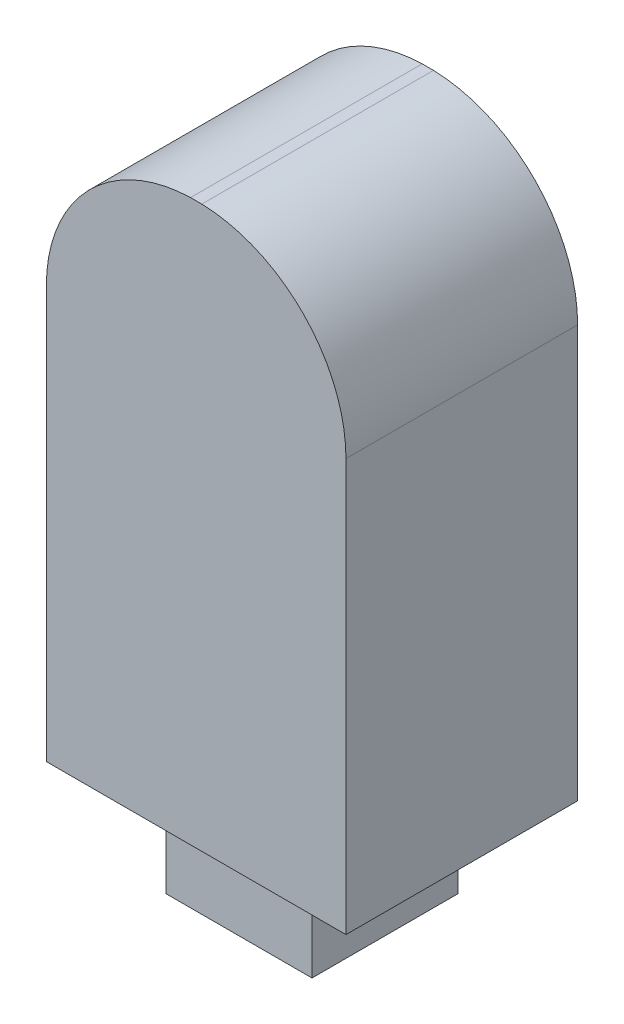
from build123d import *

# Parameters (mm, degrees)
BOSS_EXTRUDE1_DEPTH = 7.1374
SKETCH2_W           = 4.5
SKETCH2_H           = 4.5
BOSS_EXTRUDE2_DEPTH = 3


with BuildPart() as part:
    # Sketch1 → Boss-Extrude1 (new body)
    with BuildSketch(Plane.XY):
        with BuildLine():
            Line((0, 0), (0, -12.7))
            Line((0, -12.7), (9.23036, -12.7))
            Line((9.23036, -12.7), (9.23036, 0))
            ThreePointArc((9.23036, 0), (7.937079259, 3.18640613), (4.788897173, 4.570136108))
            Line((4.788897173, 4.570136108), (4.441462827, 4.570136108))
            ThreePointArc((4.441462827, 4.570136108), (1.293280741, 3.18640613), (0, 0))
        make_face()
    extrude(amount=BOSS_EXTRUDE1_DEPTH)

    # Sketch2 → Boss-Extrude2 (add)
    with BuildSketch(Plane.XZ.offset(12.7)):
        with Locations((4.61518, 3.5687)):
            Rectangle(SKETCH2_W, SKETCH2_H)
    extrude(amount=BOSS_EXTRUDE2_DEPTH)


solid = part.part
